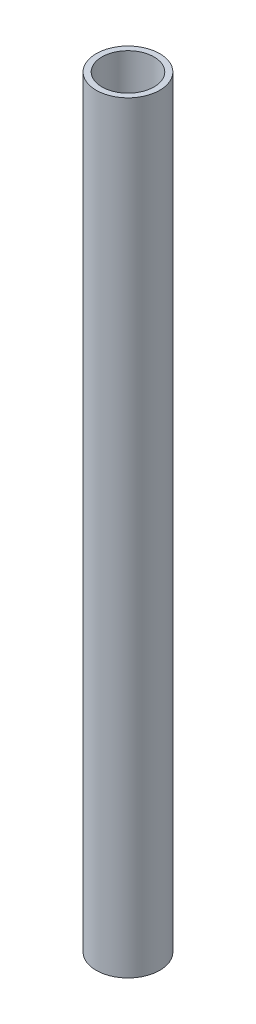
from build123d import *

# Parameters (mm, degrees)
SKETCH1_R           = 12.7
SKETCH1_R_2         = 10.414
BOSS_EXTRUDE1_DEPTH = 304.8


with BuildPart() as part:
    # Sketch1 → Boss-Extrude1 (new body)
    with BuildSketch(Plane(origin=(0, 0, 0), x_dir=(1, 0, 0), z_dir=(0, 1, 0))):
        Circle(SKETCH1_R)
        Circle(SKETCH1_R_2, mode=Mode.SUBTRACT)
    extrude(amount=BOSS_EXTRUDE1_DEPTH)


solid = part.part
